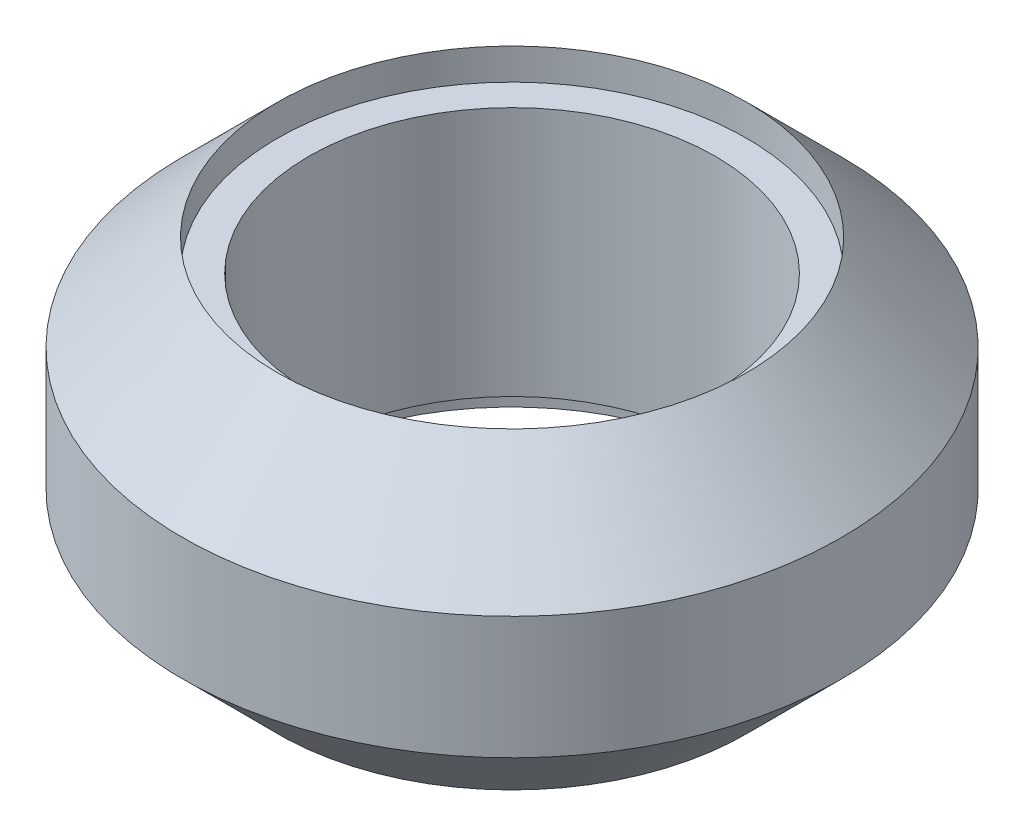
from build123d import *

# Parameters (mm, degrees)
SKETCH1_R           = 7.5
BOSS_EXTRUDE3_DEPTH = 10
SKETCH54_R          = 10.540559159
BOSS_EXTRUDE5_DEPTH = 3.040559
BOSS_EXTRUDE5_TAPER = 45
SKETCH55_R          = 10.540559159
BOSS_EXTRUDE6_DEPTH = 3.040559
BOSS_EXTRUDE6_TAPER = 45
SKETCH56_R          = 10.540559159
BOSS_EXTRUDE7_DEPTH = 3.918882
SKETCH53_R          = 6.5
CUT_EXTRUDE7_DEPTH  = 11.0000001
SKETCH57_R          = 7.5
SKETCH57_R_2        = 6.5
CUT_EXTRUDE8_DEPTH  = 1
SKETCH59_R          = 7.5
SKETCH59_R_2        = 6.5
CUT_EXTRUDE9_DEPTH  = 1


with BuildPart() as part:
    # Sketch1 → Boss-Extrude3 (new body)
    with BuildSketch(Plane(origin=(0, 0, 0), x_dir=(1, 0, 0), z_dir=(0, 1, 0))):
        Circle(SKETCH1_R)
    extrude(amount=BOSS_EXTRUDE3_DEPTH)

    # Sketch54 → Boss-Extrude5 (add)
    with BuildSketch(Plane(origin=(0, 6.959440841, 0), x_dir=(1, 0, 0), z_dir=(0, 1, 0))):
        Circle(SKETCH54_R)
    extrude(amount=BOSS_EXTRUDE5_DEPTH, taper=BOSS_EXTRUDE5_TAPER)

    # Sketch55 → Boss-Extrude6 (add)
    with BuildSketch(Plane.XZ.offset(-3.040559159)):
        Circle(SKETCH55_R)
    extrude(amount=BOSS_EXTRUDE6_DEPTH, taper=BOSS_EXTRUDE6_TAPER)

    # Sketch56 → Boss-Extrude7 (add)
    with BuildSketch(Plane(origin=(0, 6.959440841, 0), x_dir=(-1, 0, 0), z_dir=(0, -1, 0))):
        Circle(SKETCH56_R)
    extrude(amount=BOSS_EXTRUDE7_DEPTH)

    # Sketch53 → Cut-Extrude7 (cut, through all)
    with BuildSketch(Plane(origin=(0, 10, 0), x_dir=(1, 0, 0), z_dir=(0, 1, 0))):
        Circle(SKETCH53_R)
    extrude(amount=-CUT_EXTRUDE7_DEPTH, mode=Mode.SUBTRACT)

    # Sketch57 → Cut-Extrude8 (cut)
    with BuildSketch(Plane(origin=(0, 0, 0), x_dir=(-1, 0, 0), z_dir=(0, -1, 0))):
        Circle(SKETCH57_R)
        Circle(SKETCH57_R_2, mode=Mode.SUBTRACT)
    extrude(amount=-CUT_EXTRUDE8_DEPTH, mode=Mode.SUBTRACT)

    # Sketch59 → Cut-Extrude9 (cut)
    with BuildSketch(Plane(origin=(0, 10, 0), x_dir=(1, 0, 0), z_dir=(0, 1, 0))):
        Circle(SKETCH59_R)
        Circle(SKETCH59_R_2, mode=Mode.SUBTRACT)
    extrude(amount=-CUT_EXTRUDE9_DEPTH, mode=Mode.SUBTRACT)


solid = part.part
